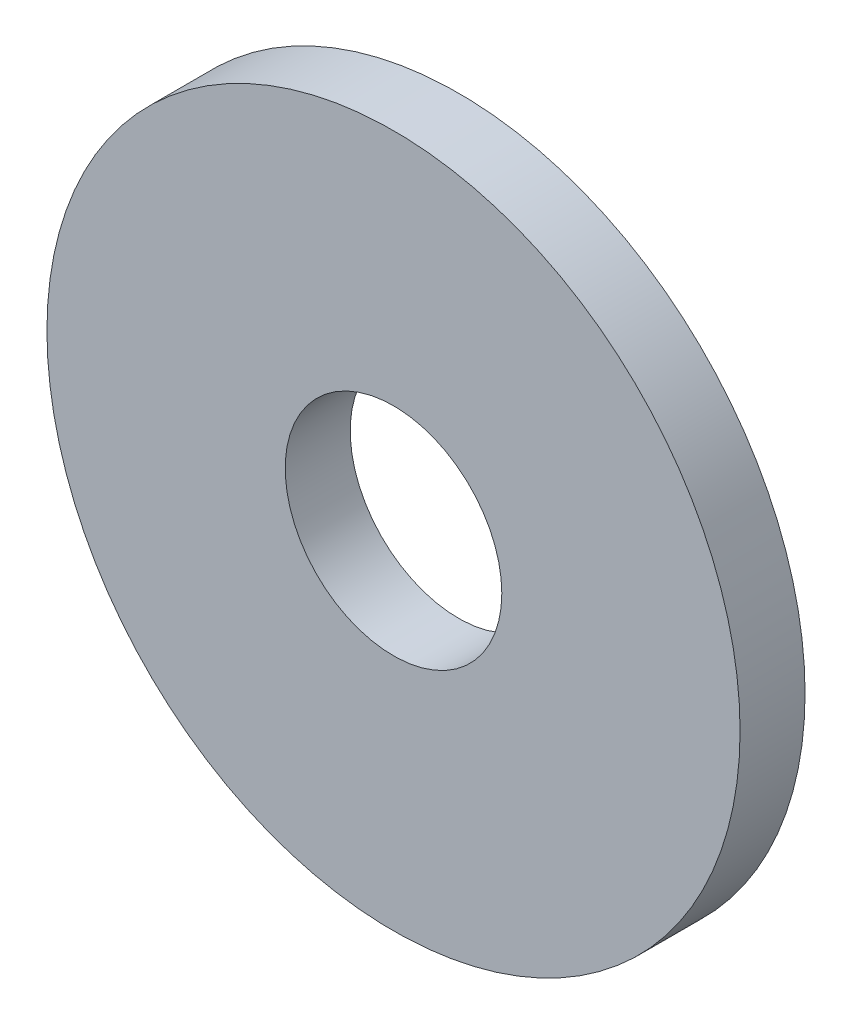
from build123d import *

# Parameters (mm, degrees)
SKETCH1_R      = 16
SKETCH1_R_2    = 5
EXTRUDE1_DEPTH = 3


with BuildPart() as part:
    # Sketch1 → Extrude1 (new body)
    with BuildSketch(Plane.XY):
        Circle(SKETCH1_R)
        Circle(SKETCH1_R_2, mode=Mode.SUBTRACT)
    extrude(amount=EXTRUDE1_DEPTH)


solid = part.part
